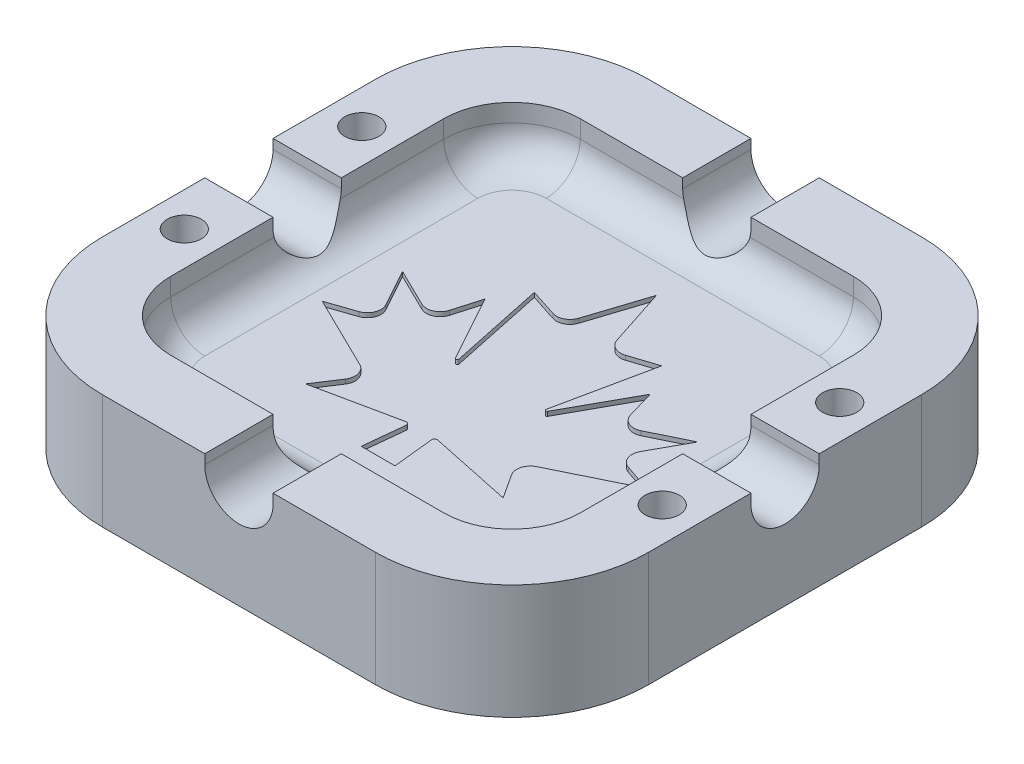
from build123d import *

# Parameters (mm, degrees)
SKETCH1_W                        = 50.8
SKETCH1_H                        = 50.8
BOSS_EXTRUDE1_DEPTH              = 10.668
CUT_EXTRUDE2_DEPTH               = 4.826
FILLET2_R                        = 12.7
FILLET1_R                        = 3.175
CUT_EXTRUDE3_DEPTH               = 29.972
CIRPATTERN1_COUNT                = 4
F_1_8_0_125_DIAMETER_HOLE1_D     = 3.175
F_1_8_0_125_DIAMETER_HOLE1_DEPTH = 4.318
F_1_8_0_125_DIAMETER_HOLE1_TIP   = 0.953866233
CUT_EXTRUDE4_DEPTH               = 0.4064
CUT_EXTRUDE9_DEPTH               = 0.381


with BuildPart() as part:
    # Sketch1 → Boss-Extrude1 (new body)
    with BuildSketch(Plane(origin=(0, 0, 0), x_dir=(1, 0, 0), z_dir=(0, 1, 0))):
        Rectangle(SKETCH1_W, SKETCH1_H)
    extrude(amount=-BOSS_EXTRUDE1_DEPTH)

    # Sketch3 → Cut-Extrude2 (cut)
    with BuildSketch(Plane(origin=(0, 0, 0), x_dir=(1, 0, 0), z_dir=(0, 1, 0))):
        with BuildLine():
            Line((19.05, -12.7), (19.05, 12.7))
            ThreePointArc((19.05, 12.7), (17.190128061, 17.190128061), (12.7, 19.05))
            Line((12.7, 19.05), (-12.7, 19.05))
            ThreePointArc((-12.7, 19.05), (-17.190128061, 17.190128061), (-19.05, 12.7))
            Line((-19.05, 12.7), (-19.05, -12.7))
            ThreePointArc((-19.05, -12.7), (-17.190128061, -17.190128061), (-12.7, -19.05))
            Line((-12.7, -19.05), (12.7, -19.05))
            ThreePointArc((12.7, -19.05), (17.190128061, -17.190128061), (19.05, -12.7))
        make_face()
    extrude(amount=-CUT_EXTRUDE2_DEPTH, mode=Mode.SUBTRACT)

    # Fillet2
    fillet2_edges = [part.edges().sort_by_distance(p)[0] for p in [
        (25.4, -5.334, -25.4),
        (25.4, -5.334, 25.4),
        (-25.4, -5.334, 25.4),
        (-25.4, -5.334, -25.4),
    ]]
    fillet(fillet2_edges, radius=FILLET2_R)

    # Fillet1
    fillet1_edges = [part.edges().sort_by_distance(p)[0] for p in [
        (17.190128061, -4.826, -17.190128061),
        (19.05, -4.826, 0),
        (17.190128061, -4.826, 17.190128061),
        (0, -4.826, 19.05),
        (-17.190128061, -4.826, 17.190128061),
        (-19.05, -4.826, 0),
        (-17.190128061, -4.826, -17.190128061),
        (0, -4.826, -19.05),
    ]]
    fillet(fillet1_edges, radius=FILLET1_R)

    # Sketch4 → Cut-Extrude3 (cut, symmetric)
    with BuildSketch(Plane(origin=(0, 0, 0), x_dir=(0, 0, -1), z_dir=(1, 0, 0))):
        with BuildLine():
            Line((-3.175, -0.889), (-3.175, 0))
            Line((-3.175, 0), (3.175, 0))
            Line((3.175, 0), (3.175, -0.889))
            ThreePointArc((3.175, -0.889), (0, -4.064), (-3.175, -0.889))
        make_face()
    cut_extrude3 = extrude(amount=CUT_EXTRUDE3_DEPTH, both=True, mode=Mode.SUBTRACT)

    # CirPattern1: Cut-Extrude3 ×4 about axis
    cirpattern1_axis = Axis((0, 50, 0), (0, -1, 0))
    for i in range(1, CIRPATTERN1_COUNT):
        add(cut_extrude3.rotate(cirpattern1_axis, i * 360 / CIRPATTERN1_COUNT), mode=Mode.SUBTRACT)

    # 1_8 _0.125_ Diameter Hole1
    with Locations(Plane(origin=(0, 0, 0), x_dir=(-1, 0, 0), z_dir=(0, 1, 0))):
        with Locations((22.225, -8.255), (22.225, 8.255), (-22.225, 8.255), (-22.225, -8.255)):
            Hole(F_1_8_0_125_DIAMETER_HOLE1_D / 2, depth=F_1_8_0_125_DIAMETER_HOLE1_DEPTH)
            with Locations((0, 0, -(F_1_8_0_125_DIAMETER_HOLE1_DEPTH + F_1_8_0_125_DIAMETER_HOLE1_TIP / 2))):  # 118° drill point
                Cone(0, F_1_8_0_125_DIAMETER_HOLE1_D / 2, F_1_8_0_125_DIAMETER_HOLE1_TIP, mode=Mode.SUBTRACT)

    # Sketch9 → Cut-Extrude4 (cut)
    with BuildSketch(Plane(origin=(0, -4.826, 0), x_dir=(1, 0, 0), z_dir=(0, 1, 0))):
        with BuildLine():
            Line((0.245965419, 13.189721505), (-1.524701959, 7.740167666))
            ThreePointArc((-1.524701959, 7.740167666), (-2.1559758, 7.001040963), (-3.124995318, 6.924777473))
            Line((-3.124995318, 6.924777473), (-5.673351017, 7.752788433))
            Line((-5.673351017, 7.752788433), (-3.805691192, -1.120846576))
            ThreePointArc((-3.805691192, -1.120846576), (-3.885723495, -1.266047211), (-4.041161593, -1.208363664))
            Line((-4.041161593, -1.208363664), (-7.430668414, 4.933904309))
            Line((-7.430668414, 4.933904309), (-8.174120801, 2.359608781))
            ThreePointArc((-8.174120801, 2.359608781), (-8.879902372, 1.550802189), (-9.953151816, 1.571571383))
            Line((-9.953151816, 1.571571383), (-13.488369392, 3.304117078))
            Line((-13.488369392, 3.304117078), (-11.586236073, -0.142818769))
            ThreePointArc((-11.586236073, -0.142818769), (-11.513386381, -1.213794329), (-12.286974379, -1.958010251))
            Line((-12.286974379, -1.958010251), (-14.822140594, -2.825564964))
            Line((-14.822140594, -2.825564964), (-7.979675595, -6.178932337))
            ThreePointArc((-7.979675595, -6.178932337), (-7.314118198, -6.982271368), (-7.474771887, -8.013052936))
            Line((-7.474771887, -8.013052936), (-8.938390113, -10.257499551))
            Line((-8.938390113, -10.257499551), (-1.233206168, -8.635767028))
            ThreePointArc((-1.233206168, -8.635767028), (-1.010744894, -8.695732142), (-0.928283654, -8.910871579))
            Line((-0.928283654, -8.910871579), (-1.326537099, -12.7))
            Line((-1.326537099, -12.7), (1.818467936, -12.7))
            Line((1.818467936, -12.7), (1.420214491, -8.910871579))
            ThreePointArc((1.420214491, -8.910871579), (1.502675731, -8.695732142), (1.725137005, -8.635767028))
            Line((1.725137005, -8.635767028), (9.43032095, -10.257499551))
            Line((9.43032095, -10.257499551), (7.966702724, -8.013052936))
            ThreePointArc((7.966702724, -8.013052936), (7.806049035, -6.982271368), (8.471606433, -6.178932337))
            Line((8.471606433, -6.178932337), (15.314071431, -2.825564964))
            Line((15.314071431, -2.825564964), (12.778905216, -1.958010251))
            ThreePointArc((12.778905216, -1.958010251), (12.005317219, -1.213794329), (12.07816691, -0.142818769))
            Line((12.07816691, -0.142818769), (13.980300229, 3.304117078))
            Line((13.980300229, 3.304117078), (10.445082653, 1.571571383))
            ThreePointArc((10.445082653, 1.571571383), (9.371833209, 1.550802189), (8.666051638, 2.359608781))
            Line((8.666051638, 2.359608781), (7.922599251, 4.933904309))
            Line((7.922599251, 4.933904309), (4.53309243, -1.208363664))
            ThreePointArc((4.53309243, -1.208363664), (4.377654333, -1.266047211), (4.297622029, -1.120846576))
            Line((4.297622029, -1.120846576), (6.165281854, 7.752788433))
            Line((6.165281854, 7.752788433), (3.616926155, 6.924777473))
            ThreePointArc((3.616926155, 6.924777473), (2.647906637, 7.001040963), (2.016632796, 7.740167666))
            Line((2.016632796, 7.740167666), (0.245965419, 13.189721505))
        make_face()
    extrude(amount=-CUT_EXTRUDE4_DEPTH, mode=Mode.SUBTRACT)

    # Sketch20 → Cut-Extrude9 (cut)
    # profile 1 of 7: a face of its own
    with BuildSketch(Plane(origin=(0, -10.668, 0), x_dir=(-1, 0, 0), z_dir=(0, -1, 0))):
        with BuildLine():
            Line((-8.400899775, 7.483094306), (-5.701084196, 16.375145144))
            Line((-5.701084196, 16.375145144), (-3.005258199, 7.476587038))
            ThreePointArc((-3.005258199, 7.476587038), (-2.023193618, 6.852371255), (-1.264678825, 7.734840231))
            Line((-1.264678825, 7.734840231), (-1.264677115, 19.430999839))
            ThreePointArc((-1.264677115, 19.430999839), (-2.153672101, 20.32), (-3.042667088, 19.430999839))
            Line((-3.042667088, 19.430999839), (-3.044746374, 13.733056577))
            Line((-3.044746374, 13.733056577), (-4.853985757, 19.695740092))
            ThreePointArc((-4.853985757, 19.695740092), (-5.702612228, 20.32), (-6.551293966, 19.695815231))
            Line((-6.551293966, 19.695815231), (-8.36053335, 13.733146647))
            Line((-8.36053335, 13.733146647), (-8.36053335, 19.437688966))
            ThreePointArc((-8.36053335, 19.437688966), (-9.249508185, 20.32), (-10.13848302, 19.437688966))
            Line((-10.13848302, 19.437688966), (-10.140554813, 7.741528728))
            ThreePointArc((-10.140554813, 7.741528728), (-9.382186642, 6.862021309), (-8.400899775, 7.483094306))
        make_face()
    # profile 2 of 7: a face of its own
    with BuildSketch(Plane(origin=(0, -10.668, 0), x_dir=(-1, 0, 0), z_dir=(0, -1, 0))):
        with BuildLine():
            Line((9.190827133, 8.630371144), (3.103366344, 8.632526645))
            Line((3.103366344, 8.632526645), (3.104807513, 12.702606601))
            Line((3.104807513, 12.702606601), (9.192268302, 12.7004511))
            ThreePointArc((9.192268302, 12.7004511), (10.081583031, 13.589136259), (9.192897872, 14.478450988))
            Line((9.192897872, 14.478450988), (3.105438135, 14.480606489))
            Line((3.105438135, 14.480606489), (3.106875497, 18.542))
            Line((3.106875497, 18.542), (9.130139232, 18.542))
            ThreePointArc((9.130139232, 18.542), (10.019139242, 19.430999995), (9.130139242, 20.32))
            Line((9.130139242, 20.32), (1.878810227, 20.32))
            ThreePointArc((1.878810227, 20.32), (1.421594617, 20.129936698), (1.233848712, 19.671764625))
            Line((1.233848712, 19.671764625), (1.295507228, 7.494075445))
            ThreePointArc((1.295507228, 7.494075445), (1.485562262, 7.040125428), (1.940468743, 6.852371255))
            Line((1.940468743, 6.852371255), (9.190197563, 6.852371255))
            ThreePointArc((9.190197563, 6.852371255), (10.079512292, 7.741056415), (9.190827133, 8.630371144))
        make_face()
    # profile 3 of 7: a face of its own
    with BuildSketch(Plane(origin=(0, -10.668, 0), x_dir=(-1, 0, 0), z_dir=(0, -1, 0))):
        with BuildLine():
            Line((-9.974701346, -4.896462803), (-9.974701346, -7.366))
            Line((-9.974701346, -7.366), (-17.877220376, -7.366))
            add(Edge.make_bspline(
                [(-17.877220376, -7.366), (-17.850046189, -7.155103844), (-17.795792924, -6.734049659), (-17.63265964, -6.116710262), (-17.406254896, -5.517309736), (-17.168564437, -5.026015759), (-16.928387373, -4.632001356), (-16.711844269, -4.309052951), (-16.4532465, -3.965457793), (-16.156743556, -3.598593289), (-15.824632394, -3.206074316), (-15.450673703, -2.793289002), (-15.039277354, -2.355620802), (-14.74805691, -2.060172255), (-14.597366286, -1.907293821)],
                knots=[0, 0, 0, 0, 1.174832724, 2.345553591, 3.520376747, 4.714220315, 5.35661523, 6.070690791, 6.863466958, 7.733549439, 8.678816056, 9.706151726, 10.813059203, 12, 12, 12, 12], degree=3))
            add(Edge.make_bspline(
                [(-14.597366286, -1.907293821), (-14.477298969, -1.784696585), (-14.248612365, -1.551191365), (-13.922607369, -1.217650245), (-13.637490613, -0.911079908), (-13.388688832, -0.636026779), (-13.172802236, -0.394444891), (-12.996271371, -0.180901995), (-12.852281813, -0.000395783), (-12.776273599, 0.115018939), (-12.742640954, 0.166088451)],
                knots=[0, 0, 0, 0, 1.478628557, 2.816274655, 4.018646068, 5.085732463, 6.012260528, 6.809752305, 7.473330888, 8, 8, 8, 8], degree=3))
            add(Edge.make_bspline(
                [(-12.742640954, 0.166088451), (-12.671431966, 0.289586984), (-12.533945914, 0.528030557), (-12.389681953, 0.904227347), (-12.295851655, 1.27703803), (-12.284962521, 1.527233379), (-12.27960273, 1.650383204)],
                knots=[0, 0, 0, 0, 1.085181023, 2.095202539, 3.062430721, 4, 4, 4, 4], degree=3))
            add(Edge.make_bspline(
                [(-12.27960273, 1.650383204), (-12.284227843, 1.77850857), (-12.292978197, 2.02091177), (-12.366351427, 2.362987509), (-12.496466944, 2.657050066), (-12.675612067, 2.904002072), (-12.902141433, 3.097488023), (-13.16696085, 3.24045536), (-13.473946849, 3.319497664), (-13.689714718, 3.329894194), (-13.802484001, 3.335327854)],
                knots=[0, 0, 0, 0, 1.193122327, 2.257294386, 3.237245624, 4.168877528, 5.075331632, 5.990371598, 6.949684428, 8, 8, 8, 8], degree=3))
            add(Edge.make_bspline(
                [(-13.802484001, 3.335327854), (-13.914491424, 3.330253221), (-14.130865584, 3.320450127), (-14.438380211, 3.234811644), (-14.707398754, 3.086562419), (-14.899115676, 2.917618127), (-15.02862955, 2.753332074), (-15.116875786, 2.6101676), (-15.192937152, 2.447488855), (-15.260333868, 2.267127329), (-15.313569654, 2.06701679), (-15.356442451, 1.848681283), (-15.390991722, 1.610945852), (-15.401979, 1.445560117), (-15.407683179, 1.359698096)],
                knots=[0, 0, 0, 0, 1.402788338, 2.709884207, 3.961032948, 5.225417836, 5.883680772, 6.578928686, 7.329201998, 8.132101139, 8.990263233, 9.922304639, 10.921339128, 12, 12, 12, 12], degree=3))
            Line((-15.407683179, 1.359698096), (-17.712584563, 1.601506947))
            add(Edge.make_bspline(
                [(-17.712584563, 1.601506947), (-17.6936502, 1.768236815), (-17.656946888, 2.091434284), (-17.56254197, 2.555244748), (-17.447013236, 2.983952959), (-17.298489361, 3.37490605), (-17.128332604, 3.731899871), (-16.926711157, 4.050269581), (-16.697971193, 4.33189347), (-16.442362253, 4.577399454), (-16.161711701, 4.786642748), (-15.869184291, 4.973919214), (-15.557553045, 5.129037462), (-15.228887806, 5.254475308), (-14.884405517, 5.356323099), (-14.521351762, 5.423401827), (-14.143260278, 5.470016809), (-13.884951071, 5.47371367), (-13.753607744, 5.475593424)],
                knots=[0, 0, 0, 0, 1.29736679, 2.514880312, 3.6573851, 4.727889563, 5.745363435, 6.711382426, 7.635388892, 8.545435522, 9.444833415, 10.33912997, 11.228988302, 12.131852284, 13.057499822, 14.003176386, 14.984668567, 16, 16, 16, 16], degree=3))
            add(Edge.make_bspline(
                [(-13.753607744, 5.475593424), (-13.610291123, 5.472745517), (-13.331444535, 5.467204435), (-12.924038107, 5.420772809), (-12.541454319, 5.340547509), (-12.180132478, 5.233969743), (-11.844565396, 5.090864176), (-11.530474004, 4.919507372), (-11.244370607, 4.710129293), (-10.979531354, 4.477909785), (-10.74414961, 4.220447695), (-10.536416573, 3.947666016), (-10.363442999, 3.657162431), (-10.221042959, 3.352121997), (-10.110249294, 3.031350074), (-10.030033014, 2.695504771), (-9.983339784, 2.343691577), (-9.977614582, 2.104127898), (-9.974701346, 1.982227265)],
                knots=[0, 0, 0, 0, 1.188400998, 2.312233984, 3.394550898, 4.427201065, 5.431043572, 6.414655761, 7.387696309, 8.365118953, 9.331457519, 10.275880316, 11.204017111, 12.129862476, 13.0632157, 14.013643874, 14.989253837, 16, 16, 16, 16], degree=3))
            add(Edge.make_bspline(
                [(-9.974701346, 1.982227265), (-9.978318867, 1.842304082), (-9.985489667, 1.564942549), (-10.038084728, 1.154197413), (-10.125153875, 0.753636184), (-10.251619522, 0.361106259), (-10.411909029, -0.032282722), (-10.618961831, -0.427792937), (-10.859264299, -0.835928378), (-11.04631211, -1.101678027), (-11.142586645, -1.23846083)],
                knots=[0, 0, 0, 0, 0.962761687, 1.908426118, 2.844839423, 3.779838542, 4.743088395, 5.764451695, 6.849351021, 8, 8, 8, 8], degree=3))
            add(Edge.make_bspline(
                [(-11.142586645, -1.23846083), (-11.178997209, -1.287697519), (-11.257064778, -1.393265471), (-11.39191667, -1.553948303), (-11.546271347, -1.731472901), (-11.721439629, -1.925074768), (-11.919917521, -2.132311577), (-12.137674301, -2.356185688), (-12.378931078, -2.593441636), (-12.632792064, -2.840353464), (-12.887402991, -3.082144199), (-13.120095135, -3.312547398), (-13.332432671, -3.516062801), (-13.514149347, -3.703075232), (-13.673837255, -3.864106088), (-13.808366822, -4.00316545), (-13.917174825, -4.120958249), (-14.068613942, -4.302336797), (-14.25916167, -4.550608064), (-14.393859456, -4.784363553), (-14.458454819, -4.896462803)],
                knots=[0, 0, 0, 0, 0.667711463, 1.431634275, 2.286736484, 3.233474166, 4.278603737, 5.416052188, 6.639405753, 7.968691487, 9.278258459, 10.468604496, 11.53993144, 12.485559988, 13.312164609, 14.013227653, 14.595739523, 15.060320576, 16.590254028, 18, 18, 18, 18], degree=3))
            Line((-14.458454819, -4.896462803), (-9.974701346, -4.896462803))
        make_face()
    # profile 4 of 7: a face of its own
    with BuildSketch(Plane(origin=(0, -10.668, 0), x_dir=(-1, 0, 0), z_dir=(0, -1, 0))):
        with BuildLine():
            add(Edge.make_bspline(
                [(-4.541719512, 5.475593424), (-4.398289633, 5.471824314), (-4.117760255, 5.464452447), (-3.709603751, 5.401525324), (-3.325259441, 5.29887743), (-2.965167108, 5.153648602), (-2.627347634, 4.968455801), (-2.318354963, 4.735694505), (-2.028485278, 4.467745346), (-1.861365457, 4.261069553), (-1.776352339, 4.155934485)],
                knots=[0, 0, 0, 0, 1.080588601, 2.113484651, 3.104355516, 4.072905502, 5.033378233, 5.998990987, 6.982095507, 8, 8, 8, 8], degree=3))
            add(Edge.make_bspline(
                [(-1.776352339, 4.155934485), (-1.680205653, 4.016595213), (-1.481143916, 3.728107706), (-1.241448944, 3.234723902), (-1.040614761, 2.679558334), (-0.873165539, 2.061005191), (-0.747463679, 1.37764332), (-0.656749675, 0.631112304), (-0.598995183, -0.179426609), (-0.593377414, -0.741019818), (-0.590459997, -1.032666063)],
                knots=[0, 0, 0, 0, 0.750617517, 1.5540757, 2.425930744, 3.36868485, 4.395157003, 5.507462469, 6.70557692, 8, 8, 8, 8], degree=3))
            add(Edge.make_bspline(
                [(-0.590459997, -1.032666063), (-0.593364839, -1.32346), (-0.598966321, -1.884205645), (-0.657068321, -2.693812435), (-0.746316208, -3.439925293), (-0.876612101, -4.12280495), (-1.045378481, -4.742542462), (-1.249833805, -5.299386581), (-1.488423242, -5.796720925), (-1.689421461, -6.086330522), (-1.786642077, -6.226411481)],
                knots=[0, 0, 0, 0, 1.288778873, 2.485186412, 3.595907217, 4.617896356, 5.563976282, 6.439470726, 7.245189249, 8, 8, 8, 8], degree=3))
            add(Edge.make_bspline(
                [(-1.786642077, -6.226411481), (-1.870863454, -6.330599538), (-2.036398747, -6.535378907), (-2.322888554, -6.802173191), (-2.633052428, -7.027770077), (-2.968228609, -7.210830949), (-3.325468896, -7.357825836), (-3.710101535, -7.45559104), (-4.117685514, -7.519765857), (-4.398264347, -7.526958392), (-4.541719512, -7.530635813)],
                knots=[0, 0, 0, 0, 1.014160545, 1.993310586, 2.956375111, 3.913128285, 4.880806607, 5.875272839, 6.913663295, 8, 8, 8, 8], degree=3))
            add(Edge.make_bspline(
                [(-4.541719512, -7.530635813), (-4.686915219, -7.526251892), (-4.971180375, -7.51766902), (-5.386181818, -7.448389535), (-5.780019006, -7.339333737), (-6.150885518, -7.179964796), (-6.500371397, -6.977700678), (-6.829919937, -6.732215732), (-7.133295665, -6.437536091), (-7.369550121, -6.161641911), (-7.542843724, -5.913566235), (-7.666120394, -5.708316706), (-7.778730349, -5.484602822), (-7.887760099, -5.246175445), (-7.985041523, -4.988189765), (-8.071853616, -4.712116279), (-8.151103911, -4.41935308), (-8.223352085, -4.109642441), (-8.287144067, -3.78266602), (-8.34444474, -3.438001248), (-8.389374147, -3.074823957), (-8.428770324, -2.694987883), (-8.456009416, -2.297688898), (-8.476584408, -1.883455445), (-8.489602019, -1.4511962), (-8.491838286, -1.15700932), (-8.492979028, -1.006941718)],
                knots=[0, 0, 0, 0, 1.212689175, 2.374211221, 3.506114229, 4.620116705, 5.737317864, 6.873770549, 8.04447299, 9.264717408, 9.902811061, 10.571320081, 11.263525821, 11.994725117, 12.761268529, 13.565755946, 14.412288902, 15.295248696, 16.222734105, 17.195768718, 18.214306769, 19.280236866, 20.386538692, 21.541611051, 22.74595177, 24, 24, 24, 24], degree=3))
            add(Edge.make_bspline(
                [(-8.492979028, -1.006941718), (-8.490051159, -0.717864001), (-8.484397814, -0.159691349), (-8.426439886, 0.646505373), (-8.336832283, 1.390842876), (-8.207178135, 2.072135366), (-8.038141171, 2.69014984), (-7.83304796, 3.244989531), (-7.595062421, 3.74169693), (-7.394032768, 4.03129413), (-7.296796948, 4.171369092)],
                knots=[0, 0, 0, 0, 1.28477466, 2.480738005, 3.590793896, 4.615651506, 5.560712253, 6.435090706, 7.243070681, 8, 8, 8, 8], degree=3))
            add(Edge.make_bspline(
                [(-7.296796948, 4.171369092), (-7.212575571, 4.275557149), (-7.047040278, 4.480336518), (-6.76055047, 4.747130802), (-6.450386597, 4.972727689), (-6.115210416, 5.155788561), (-5.757970129, 5.302783447), (-5.37333749, 5.400548651), (-4.965753511, 5.464723468), (-4.685174677, 5.471916004), (-4.541719512, 5.475593424)],
                knots=[0, 0, 0, 0, 1.014160545, 1.993310586, 2.956375111, 3.913128285, 4.880806607, 5.875272839, 6.913663295, 8, 8, 8, 8], degree=3))
        make_face()
        with BuildLine():
            add(Edge.make_bspline(
                [(-4.541719512, 3.335327854), (-4.616639716, 3.331856817), (-4.764010259, 3.325029171), (-4.97853997, 3.270956132), (-5.181529, 3.18572557), (-5.373292803, 3.063639217), (-5.547452478, 2.893154839), (-5.699928908, 2.669842036), (-5.826105631, 2.390872334), (-5.891121823, 2.184537834), (-5.925689317, 2.074834909)],
                knots=[0, 0, 0, 0, 0.882973829, 1.736839006, 2.593635661, 3.471961004, 4.402012704, 5.448757877, 6.643567974, 8, 8, 8, 8], degree=3))
            add(Edge.make_bspline(
                [(-5.925689317, 2.074834909), (-5.947262565, 1.991886319), (-5.993649592, 1.813529377), (-6.045846296, 1.522949365), (-6.088605428, 1.193168857), (-6.123404512, 0.824110542), (-6.155237978, 0.416022578), (-6.175062524, -0.031810187), (-6.183989469, -0.518999859), (-6.186678597, -0.856880231), (-6.188077644, -1.032666063)],
                knots=[0, 0, 0, 0, 0.657749768, 1.414300538, 2.264250862, 3.210039543, 4.259623417, 5.406177268, 6.650536329, 8, 8, 8, 8], degree=3))
            add(Edge.make_bspline(
                [(-6.188077644, -1.032666063), (-6.188154531, -1.207604519), (-6.188301923, -1.54295861), (-6.173730902, -2.024012374), (-6.157063504, -2.462326812), (-6.132050771, -2.858704807), (-6.097955181, -3.212799572), (-6.062321533, -3.524975), (-6.012560557, -3.793343915), (-5.944640506, -4.085161549), (-5.840292086, -4.389892551), (-5.700439261, -4.698472833), (-5.549583694, -4.945888714), (-5.370704316, -5.122543615), (-5.178257221, -5.242649069), (-4.97834228, -5.329981454), (-4.763561615, -5.379121207), (-4.616555362, -5.386575511), (-4.541719512, -5.390370242)],
                knots=[0, 0, 0, 0, 1.630545351, 3.125728145, 4.485651025, 5.719130445, 6.827016481, 7.801545019, 8.646551661, 9.369665776, 10.593004059, 11.640819758, 12.525421549, 13.277124778, 13.960027631, 14.629610262, 15.302381512, 16, 16, 16, 16], degree=3))
            add(Edge.make_bspline(
                [(-4.541719512, -5.390370242), (-4.466828913, -5.386784655), (-4.318682719, -5.379691759), (-4.103711847, -5.327020069), (-3.901225478, -5.240130036), (-3.710203496, -5.117873606), (-3.532892764, -4.95000318), (-3.384750929, -4.723134016), (-3.253344101, -4.447284656), (-3.190871726, -4.23985417), (-3.157749708, -4.129877298)],
                knots=[0, 0, 0, 0, 0.882622435, 1.745975536, 2.593127185, 3.471102984, 4.408070702, 5.448666223, 6.647316915, 8, 8, 8, 8], degree=3))
            add(Edge.make_bspline(
                [(-3.157749708, -4.129877298), (-3.136222056, -4.046921311), (-3.09014485, -3.869364552), (-3.037301318, -3.580612428), (-2.995649616, -3.252336301), (-2.955756013, -2.885457616), (-2.929436122, -2.477763954), (-2.907989122, -2.030980347), (-2.89957832, -1.544608418), (-2.896802265, -1.2075914), (-2.895361381, -1.032666063)],
                knots=[0, 0, 0, 0, 0.659890695, 1.412412254, 2.258583172, 3.208116528, 4.254052314, 5.404338112, 6.652747471, 8, 8, 8, 8], degree=3))
            add(Edge.make_bspline(
                [(-2.895361381, -1.032666063), (-2.895276357, -0.857726825), (-2.895113367, -0.522371233), (-2.909816864, -0.040471273), (-2.926173193, 0.398732836), (-2.95172194, 0.795029663), (-2.984121145, 1.148647867), (-3.025872995, 1.45899975), (-3.068914574, 1.728800947), (-3.144043073, 2.019502156), (-3.241423068, 2.327060057), (-3.38317413, 2.635728604), (-3.534536099, 2.883344022), (-3.712691982, 3.061912779), (-3.9043898, 3.185608862), (-4.105569352, 3.271433241), (-4.319454734, 3.324955356), (-4.466808061, 3.331831938), (-4.541719512, 3.335327854)],
                knots=[0, 0, 0, 0, 1.628671121, 3.122135279, 4.488471861, 5.72053346, 6.819197896, 7.793620656, 8.636257813, 9.360435521, 10.587416858, 11.634028146, 12.517613132, 13.274076342, 13.960525479, 14.629338458, 15.30318339, 16, 16, 16, 16], degree=3))
        make_face(mode=Mode.SUBTRACT)
    # profile 5 of 7: a face of its own
    with BuildSketch(Plane(origin=(0, -10.668, 0), x_dir=(-1, 0, 0), z_dir=(0, -1, 0))):
        with BuildLine():
            Line((8.793781352, -4.896462803), (8.793781352, -7.366))
            Line((8.793781352, -7.366), (0.891262321, -7.366))
            add(Edge.make_bspline(
                [(0.891262321, -7.366), (0.918436508, -7.155103844), (0.972689774, -6.734049659), (1.135823058, -6.116710262), (1.362227802, -5.517309736), (1.59991826, -5.026015759), (1.840095324, -4.632001356), (2.056638428, -4.309052951), (2.315236197, -3.965457793), (2.611739141, -3.598593289), (2.943850303, -3.206074316), (3.317808995, -2.793289002), (3.729205344, -2.355620802), (4.020425788, -2.060172255), (4.171116411, -1.907293821)],
                knots=[0, 0, 0, 0, 1.174832724, 2.345553591, 3.520376747, 4.714220315, 5.35661523, 6.070690791, 6.863466958, 7.733549439, 8.678816056, 9.706151726, 10.813059203, 12, 12, 12, 12], degree=3))
            add(Edge.make_bspline(
                [(4.171116411, -1.907293821), (4.291183729, -1.784696585), (4.519870333, -1.551191365), (4.845875328, -1.217650245), (5.130992084, -0.911079908), (5.379793865, -0.636026779), (5.595680462, -0.394444891), (5.772211326, -0.180901995), (5.916200884, -0.000395783), (5.992209098, 0.115018939), (6.025841743, 0.166088451)],
                knots=[0, 0, 0, 0, 1.478628557, 2.816274655, 4.018646068, 5.085732463, 6.012260528, 6.809752305, 7.473330888, 8, 8, 8, 8], degree=3))
            add(Edge.make_bspline(
                [(6.025841743, 0.166088451), (6.097050732, 0.289586984), (6.234536783, 0.528030557), (6.378800744, 0.904227347), (6.472631043, 1.27703803), (6.483520176, 1.527233379), (6.488879968, 1.650383204)],
                knots=[0, 0, 0, 0, 1.085181023, 2.095202539, 3.062430721, 4, 4, 4, 4], degree=3))
            add(Edge.make_bspline(
                [(6.488879968, 1.650383204), (6.484254854, 1.77850857), (6.4755045, 2.02091177), (6.40213127, 2.362987509), (6.272015753, 2.657050066), (6.09287063, 2.904002072), (5.866341264, 3.097488023), (5.601521847, 3.24045536), (5.294535849, 3.319497664), (5.078767979, 3.329894194), (4.965998696, 3.335327854)],
                knots=[0, 0, 0, 0, 1.193122327, 2.257294386, 3.237245624, 4.168877528, 5.075331632, 5.990371598, 6.949684428, 8, 8, 8, 8], degree=3))
            add(Edge.make_bspline(
                [(4.965998696, 3.335327854), (4.853991273, 3.330253221), (4.637617114, 3.320450127), (4.330102486, 3.234811644), (4.061083943, 3.086562419), (3.869367022, 2.917618127), (3.739853147, 2.753332074), (3.651606912, 2.6101676), (3.575545546, 2.447488855), (3.508148829, 2.267127329), (3.454913043, 2.06701679), (3.412040247, 1.848681283), (3.377490975, 1.610945852), (3.366503697, 1.445560117), (3.360799518, 1.359698096)],
                knots=[0, 0, 0, 0, 1.402788338, 2.709884207, 3.961032948, 5.225417836, 5.883680772, 6.578928686, 7.329201998, 8.132101139, 8.990263233, 9.922304639, 10.921339128, 12, 12, 12, 12], degree=3))
            Line((3.360799518, 1.359698096), (1.055898134, 1.601506947))
            add(Edge.make_bspline(
                [(1.055898134, 1.601506947), (1.074832498, 1.768236815), (1.111535809, 2.091434284), (1.205940727, 2.555244748), (1.321469462, 2.983952959), (1.469993336, 3.37490605), (1.640150093, 3.731899871), (1.84177154, 4.050269581), (2.070511504, 4.33189347), (2.326120445, 4.577399454), (2.606770997, 4.786642748), (2.899298406, 4.973919214), (3.210929653, 5.129037462), (3.539594891, 5.254475308), (3.88407718, 5.356323099), (4.247130935, 5.423401827), (4.62522242, 5.470016809), (4.883531626, 5.47371367), (5.014874953, 5.475593424)],
                knots=[0, 0, 0, 0, 1.29736679, 2.514880312, 3.6573851, 4.727889563, 5.745363435, 6.711382426, 7.635388892, 8.545435522, 9.444833415, 10.33912997, 11.228988302, 12.131852284, 13.057499822, 14.003176386, 14.984668567, 16, 16, 16, 16], degree=3))
            add(Edge.make_bspline(
                [(5.014874953, 5.475593424), (5.158191575, 5.472745517), (5.437038162, 5.467204435), (5.84444459, 5.420772809), (6.227028378, 5.340547509), (6.588350219, 5.233969743), (6.923917301, 5.090864176), (7.238008693, 4.919507372), (7.52411209, 4.710129293), (7.788951343, 4.477909785), (8.024333087, 4.220447695), (8.232066124, 3.947666016), (8.405039698, 3.657162431), (8.547439739, 3.352121997), (8.658233403, 3.031350074), (8.738449684, 2.695504771), (8.785142913, 2.343691577), (8.790868115, 2.104127898), (8.793781352, 1.982227265)],
                knots=[0, 0, 0, 0, 1.188400998, 2.312233984, 3.394550898, 4.427201065, 5.431043572, 6.414655761, 7.387696309, 8.365118953, 9.331457519, 10.275880316, 11.204017111, 12.129862476, 13.0632157, 14.013643874, 14.989253837, 16, 16, 16, 16], degree=3))
            add(Edge.make_bspline(
                [(8.793781352, 1.982227265), (8.790163831, 1.842304082), (8.782993031, 1.564942549), (8.730397969, 1.154197413), (8.643328822, 0.753636184), (8.516863175, 0.361106259), (8.356573669, -0.032282722), (8.149520866, -0.427792937), (7.909218398, -0.835928378), (7.722170587, -1.101678027), (7.625896052, -1.23846083)],
                knots=[0, 0, 0, 0, 0.962761687, 1.908426118, 2.844839423, 3.779838542, 4.743088395, 5.764451695, 6.849351021, 8, 8, 8, 8], degree=3))
            add(Edge.make_bspline(
                [(7.625896052, -1.23846083), (7.589485488, -1.287697519), (7.511417919, -1.393265471), (7.376566027, -1.553948303), (7.22221135, -1.731472901), (7.047043069, -1.925074768), (6.848565177, -2.132311577), (6.630808396, -2.356185688), (6.38955162, -2.593441636), (6.135690633, -2.840353464), (5.881079707, -3.082144199), (5.648387562, -3.312547398), (5.436050027, -3.516062801), (5.254333351, -3.703075232), (5.094645442, -3.864106088), (4.960115875, -4.00316545), (4.851307872, -4.120958249), (4.699868755, -4.302336797), (4.509321028, -4.550608064), (4.374623242, -4.784363553), (4.310027878, -4.896462803)],
                knots=[0, 0, 0, 0, 0.667711463, 1.431634275, 2.286736484, 3.233474166, 4.278603737, 5.416052188, 6.639405753, 7.968691487, 9.278258459, 10.468604496, 11.53993144, 12.485559988, 13.312164609, 14.013227653, 14.595739523, 15.060320576, 16.590254028, 18, 18, 18, 18], degree=3))
            Line((4.310027878, -4.896462803), (8.793781352, -4.896462803))
        make_face()
    # profile 6 of 7: a face of its own
    with BuildSketch(Plane(origin=(0, -10.668, 0), x_dir=(-1, 0, 0), z_dir=(0, -1, 0))):
        Polygon((14.885306437, -7.366), (14.885306437, -4.73182699), (9.946232043, -4.73182699), (9.946232043, -2.599278723), (15.191426153, 5.310957611), (17.190207821, 5.310957611), (17.190207821, -2.591561419), (18.67193014, -2.591561419), (18.67193014, -4.73182699), (17.190207821, -4.73182699), (17.190207821, -7.366), align=None)
        Polygon((14.885306437, -2.591561419), (14.885306437, 1.511471736), (12.163670652, -2.591561419), align=None, mode=Mode.SUBTRACT)
    # profile 7 of 7: a face of its own
    with BuildSketch(Plane(origin=(0, -10.668, 0), x_dir=(-1, 0, 0), z_dir=(0, -1, 0))):
        with BuildLine():
            Line((-0.228966346, -20.591367521), (-1.912293002, -19.743344017))
            Line((-1.912293002, -19.743344017), (-0.06784188, -16.113803419))
            add(Edge.make_bspline(
                [(-0.06784188, -16.113803419), (-0.176816287, -16.111025806), (-0.390759412, -16.10557268), (-0.705773974, -16.060257254), (-1.007014816, -15.982900928), (-1.298032574, -15.879920172), (-1.574802565, -15.741863797), (-1.840680847, -15.577100758), (-2.091986765, -15.379140335), (-2.329898588, -15.156624634), (-2.547119685, -14.910672759), (-2.735663003, -14.64615568), (-2.900000191, -14.36978342), (-3.027797803, -14.075316675), (-3.130445495, -13.768243575), (-3.205445074, -13.446974675), (-3.247532854, -13.110100453), (-3.253415535, -12.880827542), (-3.256410256, -12.764110577)],
                knots=[0, 0, 0, 0, 1.014336294, 1.991387562, 2.955278539, 3.906441712, 4.859855302, 5.829322156, 6.813833455, 7.833278715, 8.858926674, 9.863225732, 10.85404919, 11.846815163, 12.845559416, 13.865450493, 14.913355531, 16, 16, 16, 16], degree=3))
            add(Edge.make_bspline(
                [(-3.256410256, -12.764110577), (-3.253632489, -12.650896271), (-3.248158955, -12.427809823), (-3.202700728, -12.100391516), (-3.127888252, -11.786022107), (-3.025248215, -11.484755002), (-2.888608207, -11.198621699), (-2.728674555, -10.923142012), (-2.533162921, -10.66401532), (-2.312301289, -10.420119863), (-2.070579953, -10.196998584), (-1.814133907, -10.000820453), (-1.544129173, -9.836834386), (-1.264035578, -9.699116342), (-0.968790229, -9.596221987), (-0.66265975, -9.518588958), (-0.343363673, -9.473783605), (-0.126632155, -9.468149929), (-0.01696047, -9.465299145)],
                knots=[0, 0, 0, 0, 1.055538678, 2.079917126, 3.075849687, 4.065898488, 5.041806164, 6.028602842, 7.031727914, 8.062953097, 9.093756959, 10.095582084, 11.068815425, 12.035667573, 13.000833448, 13.979119574, 14.977382875, 16, 16, 16, 16], degree=3))
            add(Edge.make_bspline(
                [(-0.01696047, -9.465299145), (0.097714543, -9.467659606), (0.323207442, -9.472301134), (0.653298763, -9.523518559), (0.969116779, -9.602095458), (1.271944708, -9.708818917), (1.55802307, -9.853664741), (1.829745621, -10.027263469), (2.086208526, -10.233456088), (2.324657561, -10.466299487), (2.541524294, -10.719560249), (2.733749668, -10.984663169), (2.895227143, -11.261089897), (3.027487073, -11.546373418), (3.130516893, -11.840960663), (3.201336763, -12.145269493), (3.248353302, -12.458779527), (3.253702846, -12.671362498), (3.256410256, -12.778950988)],
                knots=[0, 0, 0, 0, 1.062826075, 2.08990367, 3.089830715, 4.078784409, 5.060762809, 6.057138927, 7.064407536, 8.107320944, 9.143871033, 10.153461498, 11.140480137, 12.108246174, 13.065926856, 14.029354859, 15.002654194, 16, 16, 16, 16], degree=3))
            add(Edge.make_bspline(
                [(3.256410256, -12.778950988), (3.254932797, -12.861006175), (3.251956863, -13.02628377), (3.222695212, -13.274135439), (3.178299393, -13.522674054), (3.126768647, -13.731633387), (3.072745829, -13.907773412), (3.020175474, -14.057195557), (2.952726162, -14.223082194), (2.877412263, -14.406545222), (2.790189904, -14.606780134), (2.68925069, -14.822829731), (2.58069511, -15.057898242), (2.500678931, -15.218634886), (2.459268162, -15.301820913)],
                knots=[0, 0, 0, 0, 1.105131805, 2.225983929, 3.357782449, 4.505488967, 5.122909461, 5.839607681, 6.638776516, 7.535249922, 8.51168636, 9.581005249, 10.748097757, 12, 12, 12, 12], degree=3))
            Line((2.459268162, -15.301820913), (-0.228966346, -20.591367521))
        make_face()
        with BuildLine():
            add(Edge.make_bspline(
                [(0.025440705, -14.34991453), (0.116460312, -14.344555942), (0.294292016, -14.334086474), (0.549735432, -14.253134319), (0.778344302, -14.114603196), (0.980968643, -13.930562755), (1.148411196, -13.706024997), (1.270152888, -13.45040872), (1.345142024, -13.169007454), (1.352864193, -12.973058429), (1.356837607, -12.872233574)],
                knots=[0, 0, 0, 0, 0.984774978, 1.924027336, 2.867853169, 3.859505234, 4.871392407, 5.881338128, 6.909850265, 8, 8, 8, 8], degree=3))
            add(Edge.make_bspline(
                [(1.356837607, -12.872233574), (1.352052063, -12.769311328), (1.342743037, -12.569102988), (1.267035536, -12.280947014), (1.137666645, -12.020471103), (0.961667669, -11.794045804), (0.75619116, -11.604556755), (0.526416556, -11.466140108), (0.277923264, -11.38054769), (0.105957212, -11.370133174), (0.019080529, -11.364871795)],
                knots=[0, 0, 0, 0, 1.104110315, 2.147758178, 3.172670271, 4.206310416, 5.210906102, 6.157051016, 7.068948237, 8, 8, 8, 8], degree=3))
            add(Edge.make_bspline(
                [(0.019080529, -11.364871795), (-0.072743249, -11.37000096), (-0.253038486, -11.380072035), (-0.511654617, -11.46545891), (-0.750058092, -11.601217496), (-0.958250429, -11.791349473), (-1.138432913, -12.014792824), (-1.264079078, -12.276147956), (-1.343567199, -12.562293066), (-1.352334601, -12.762860444), (-1.356837607, -12.865873397)],
                knots=[0, 0, 0, 0, 0.970967322, 1.90648639, 2.855811969, 3.858352357, 4.877096915, 5.878517833, 6.91039038, 8, 8, 8, 8], degree=3))
            add(Edge.make_bspline(
                [(-1.356837607, -12.865873397), (-1.352133939, -12.967417977), (-1.342985795, -13.164911582), (-1.266315052, -13.447908786), (-1.141426093, -13.704877805), (-0.970693978, -13.931186362), (-0.760394055, -14.116133591), (-0.521614684, -14.253189077), (-0.25526182, -14.334305976), (-0.069811124, -14.344618021), (0.025440705, -14.34991453)],
                knots=[0, 0, 0, 0, 1.075706617, 2.092137047, 3.084482865, 4.090466434, 5.0784141, 6.035155512, 6.990809768, 8, 8, 8, 8], degree=3))
        make_face(mode=Mode.SUBTRACT)
    extrude(amount=-CUT_EXTRUDE9_DEPTH, mode=Mode.SUBTRACT)


solid = part.part
